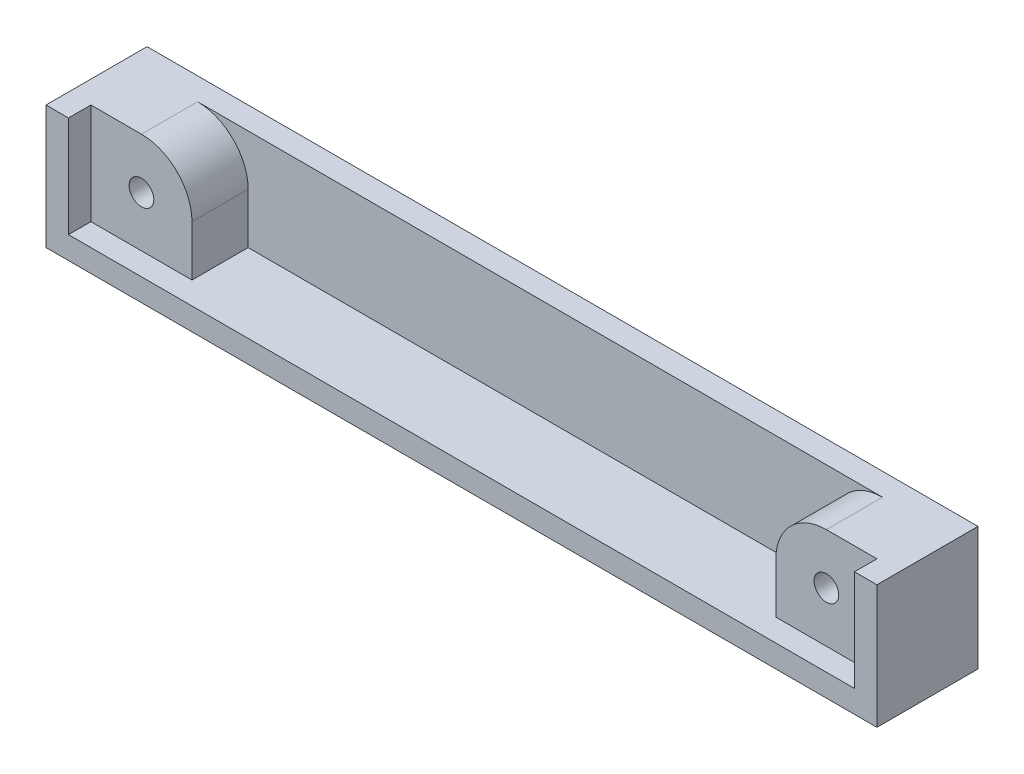
from build123d import *

# Parameters (mm, degrees)
SKETCH_1_W        = 9
SKETCH_1_H        = 9
SKETCH_1_R        = 1.1
EXTRUDE_1_DEPTH   = 7
EXTRUDE_1_2_DEPTH = 7
SKETCH_1_3_W      = 52
SKETCH_1_3_H      = 9
EXTRUDE_2_DEPTH   = 2
EXTRUDE_3_DEPTH   = 9
FILLET_1_R        = 4.5


with BuildPart() as part:
    # Эскиз1 → Бобышка-Вытянуть1 (new body)
    with BuildSketch(Plane.XY):
        with Locations((6.5, 6.5)):
            Rectangle(SKETCH_1_W, SKETCH_1_H)
        with Locations((6.5, 6.5)):
            Circle(SKETCH_1_R, mode=Mode.SUBTRACT)
    extrude(amount=EXTRUDE_1_DEPTH)



with BuildPart() as body_2:
    # Эскиз1 → Extrude 1 2 (new body)
    with BuildSketch(Plane.XY):
        with Locations((67.5, 6.5)):
            Rectangle(SKETCH_1_W, SKETCH_1_H)
        with Locations((67.5, 6.5)):
            Circle(SKETCH_1_R, mode=Mode.SUBTRACT)
    extrude(amount=EXTRUDE_1_2_DEPTH)


with BuildPart() as part_1:
    add(part.part)

    add(body_2.part)  # Бобышка-Вытянуть2 merges body 2
    # Эскиз1<3> → Бобышка-Вытянуть2 (add)
    with BuildSketch(Plane.XY):
        with Locations((37, 6.5)):
            Rectangle(SKETCH_1_3_W, SKETCH_1_3_H)
    extrude(amount=EXTRUDE_2_DEPTH)

    # Эскиз1<4> → Бобышка-Вытянуть3 (add)
    with BuildSketch(Plane.XY):
        Polygon((0, 11), (0, 0), (74, 0), (74, 11), (72, 11), (72, 2), (63, 2), (11, 2), (2, 2), (2, 11), align=None)
    extrude(amount=EXTRUDE_3_DEPTH)

    # Скругление1
    fillet_1_edges = [part_1.edges().sort_by_distance(p)[0] for p in [
        (63, 11, 4.5),
        (11, 11, 4.5),
    ]]
    fillet(fillet_1_edges, radius=FILLET_1_R)


solid = part_1.part
